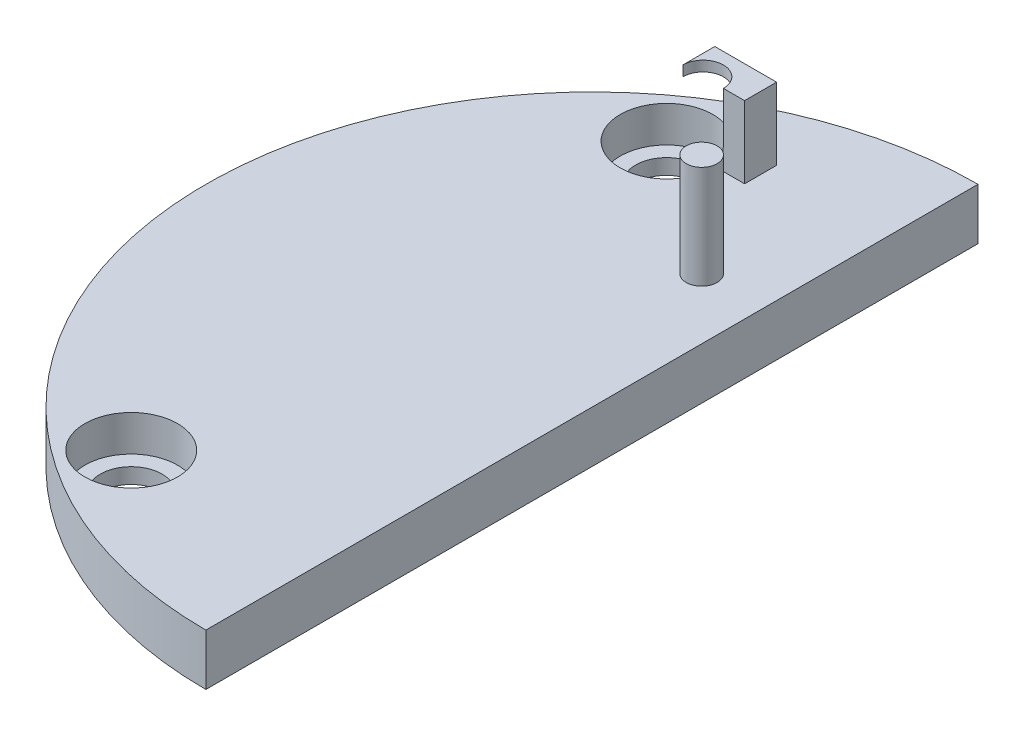
from build123d import *

# Parameters (mm, degrees)
AUFSATZ_LINEAR_AUSTRAGEN1_DEPTH = 5
SKIZZE11_R                      = 4.5
SCHNITT_LINEAR_AUSTRAGEN1_DEPTH = 3.5
SKIZZE12_R                      = 3
SCHNITT_LINEAR_AUSTRAGEN2_DEPTH = 1.5
SKIZZE13_W                      = 2.085762608
SKIZZE13_H                      = 3.10677117
AUFSATZ_LINEAR_AUSTRAGEN2_DEPTH = 6
SKIZZE14_W                      = 6
SKIZZE14_H                      = 3.10677117
AUFSATZ_LINEAR_AUSTRAGEN3_DEPTH = 1
SCHNITT_LINEAR_AUSTRAGEN3_DEPTH = 5
SKIZZE17_R                      = 1.5
AUFSATZ_LINEAR_AUSTRAGEN4_DEPTH = 10


with BuildPart() as part:
    # Skizze1 → Aufsatz-Linear austragen1 (new body)
    with BuildSketch(Plane(origin=(0, 0, 0), x_dir=(1, 0, 0), z_dir=(0, 1, 0))):
        with BuildLine():
            Line((0, 0), (0, -75))
            ThreePointArc((0, -75), (-37.5, -37.5), (0, 0))
        make_face()
    extrude(amount=AUFSATZ_LINEAR_AUSTRAGEN1_DEPTH)

    # Skizze11 → Schnitt-Linear austragen1 (cut)
    with BuildSketch(Plane(origin=(0, 5, 0), x_dir=(1, 0, 0), z_dir=(0, 1, 0))):
        with Locations((-18.75, -11.5)):
            Circle(SKIZZE11_R)
        with Locations((-18.75, -63.5)):
            Circle(SKIZZE11_R)
    extrude(amount=-SCHNITT_LINEAR_AUSTRAGEN1_DEPTH, mode=Mode.SUBTRACT)

    # Skizze12 → Schnitt-Linear austragen2 (cut)
    with BuildSketch(Plane(origin=(0, 1.5, 0), x_dir=(1, 0, 0), z_dir=(0, 1, 0))):
        with Locations((-18.75, -63.5)):
            Circle(SKIZZE12_R)
        with Locations((-18.75, -11.5)):
            Circle(SKIZZE12_R)
    extrude(amount=-SCHNITT_LINEAR_AUSTRAGEN2_DEPTH, mode=Mode.SUBTRACT)

    # Skizze13 → Aufsatz-Linear austragen2 (add)
    with BuildSketch(Plane(origin=(0, 5, 0), x_dir=(1, 0, 0), z_dir=(0, 1, 0))):
        with Locations((-12.416205268, -9.745021236)):
            Rectangle(SKIZZE13_W, SKIZZE13_H)
    extrude(amount=AUFSATZ_LINEAR_AUSTRAGEN2_DEPTH)

    # Skizze14 → Aufsatz-Linear austragen3 (add)
    with BuildSketch(Plane(origin=(0, 11, 0), x_dir=(1, 0, 0), z_dir=(0, 1, 0))):
        with Locations((-14.373323964, -9.745021236)):
            Rectangle(SKIZZE14_W, SKIZZE14_H)
    extrude(amount=AUFSATZ_LINEAR_AUSTRAGEN3_DEPTH)

    # Skizze16 → Schnitt-Linear austragen3 (cut)
    with BuildSketch(Plane(origin=(0, 12, 0), x_dir=(1, 0, 0), z_dir=(0, 1, 0))):
        with BuildLine():
            Line((-17.373323964, -11.298406821), (-13.43004884, -11.298406821))
            ThreePointArc((-13.43004884, -11.298406821), (-15.401686402, -9.326769259), (-17.373323964, -11.298406821))
        make_face()
    extrude(amount=-SCHNITT_LINEAR_AUSTRAGEN3_DEPTH, mode=Mode.SUBTRACT)

    # Skizze17 → Aufsatz-Linear austragen4 (add)
    with BuildSketch(Plane(origin=(0, 5, 0), x_dir=(1, 0, 0), z_dir=(0, 1, 0))):
        with Locations((-5.905120945, -20.937212942)):
            Circle(SKIZZE17_R)
    extrude(amount=AUFSATZ_LINEAR_AUSTRAGEN4_DEPTH)


solid = part.part
